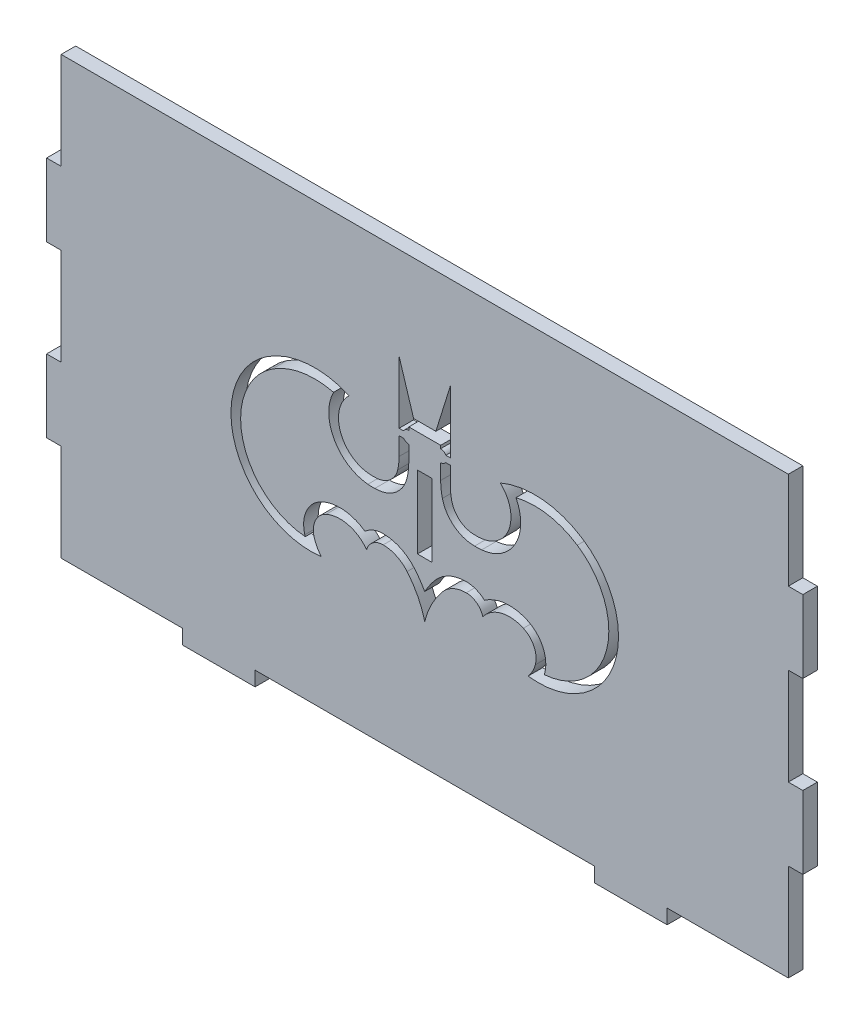
from build123d import *

# Parameters (mm, degrees)
BOSS_EXTRUDE1_DEPTH = 3
SKETCH2_W           = 3
SKETCH2_H           = 15
CUT_EXTRUDE1_DEPTH  = 10
CUT_EXTRUDE5_DEPTH  = 10


with BuildPart() as part:
    # Sketch1 → Boss-Extrude1 (new body)
    with BuildSketch(Plane.XY):
        Polygon((75, 45), (-75, 45), (-75, 25), (-78, 25), (-78, 10), (-75, 10), (-75, -10), (-78, -10), (-78, -25), (-75, -25), (-75, -45), (-50, -45), (-50, -48), (-35, -48), (-35, -45), (35, -45), (35, -48), (50, -48), (50, -45), (75, -45), (75, -25), (78, -25), (78, -10), (75, -10), (75, 10), (78, 10), (78, 25), (75, 25), align=None)
    extrude(amount=BOSS_EXTRUDE1_DEPTH)

    # Sketch2 → Cut-Extrude1 (cut)
    with BuildSketch(Plane.XY.offset(3)):
        Rectangle(SKETCH2_W, SKETCH2_H)
    extrude(amount=-CUT_EXTRUDE1_DEPTH, mode=Mode.SUBTRACT)

    # Sketch6 → Cut-Extrude5 (cut)
    with BuildSketch(Plane.XY.offset(3)):
        with BuildLine():
            Line((5.290512726, 25.935056248), (2.295363862, 16.311934545))
            Line((2.295363862, 16.311934545), (-2.295363862, 16.311934545))
            Line((-2.295363862, 16.311934545), (-5.290512726, 25.935056248))
            Line((-5.290512726, 25.935056248), (-5.287204108, 13.065687756))
            Line((-5.287204108, 13.065687756), (-4.373165869, 13.065687756))
            ThreePointArc((-4.373165869, 13.065687756), (-3.915305203, 13.527588879), (-3.287366333, 13.696945937))
            Line((-3.287366333, 13.696945937), (-3.287524442, 14.311934545))
            Line((-3.287524442, 14.311934545), (3.287524442, 14.311934545))
            Line((3.287524442, 14.311934545), (3.287366333, 13.696945937))
            ThreePointArc((3.287366333, 13.696945937), (3.915305203, 13.527588879), (4.373165869, 13.065687756))
            Line((4.373165869, 13.065687756), (5.287204108, 13.065687756))
            Line((5.287204108, 13.065687756), (5.290512726, 25.935056248))
        make_face()
        with BuildLine():
            Line((5.285908962, 8.028025182), (5.2868631, 11.739287))
            Line((5.2868631, 11.739287), (4.317442352, 11.739287))
            ThreePointArc((4.317442352, 11.739287), (3.869108183, 11.340735142), (3.286723602, 11.19694602))
            Line((3.286723602, 11.19694602), (3.285909029, 8.028539367))
            ThreePointArc((3.285909029, 8.028539367), (3.374432245, 6.505542997), (3.639582158, 5.003194892))
            ThreePointArc((3.639582158, 5.003194892), (6.055992917, 1.239562801), (10.295107821, -0.186576152))
            ThreePointArc((10.295107821, -0.186576152), (11.01438813, -0.194494412), (11.732516685, -0.153042755))
            ThreePointArc((11.732516685, -0.153042755), (18.692972821, 4.404939535), (18.821664118, 12.723989405))
            ThreePointArc((18.821664118, 12.723989405), (25.37715821, 12.9694755), (31.476327164, 10.553920845))
            ThreePointArc((31.476327164, 10.553920845), (37.518458896, -5.149561028), (24.647485484, -15.98675357))
            ThreePointArc((24.647485484, -15.98675357), (24.695354215, -15.831004559), (24.740416096, -15.674420407))
            ThreePointArc((24.740416096, -15.674420407), (24.374260224, -11.19523634), (21.190905903, -8.022947688))
            ThreePointArc((21.190905903, -8.022947688), (16.646624705, -7.250909085), (12.327665086, -8.861226761))
            ThreePointArc((12.327665086, -8.861226761), (10.583620787, -7.776302438), (8.564637884, -7.398864573))
            ThreePointArc((8.564637884, -7.398864573), (5.000034739, -8.19121848), (2.10219111, -10.413092149))
            ThreePointArc((2.10219111, -10.413092149), (0.980226646, -11.88188736), (0, -13.448833229))
            ThreePointArc((0, -13.448833229), (-0.980226646, -11.88188736), (-2.10219111, -10.413092149))
            ThreePointArc((-2.10219111, -10.413092149), (-5.000034739, -8.19121848), (-8.564637884, -7.398864573))
            ThreePointArc((-8.564637884, -7.398864573), (-10.583620787, -7.776302438), (-12.327665086, -8.861226761))
            ThreePointArc((-12.327665086, -8.861226761), (-16.646624705, -7.250909085), (-21.190905903, -8.022947688))
            ThreePointArc((-21.190905903, -8.022947688), (-24.374260224, -11.19523634), (-24.740416096, -15.674420407))
            ThreePointArc((-24.740416096, -15.674420407), (-24.695354215, -15.831004559), (-24.647485484, -15.98675357))
            ThreePointArc((-24.647485484, -15.98675357), (-37.518458896, -5.149561028), (-31.476327164, 10.553920845))
            ThreePointArc((-31.476327164, 10.553920845), (-25.37715821, 12.9694755), (-18.821664118, 12.723989405))
            ThreePointArc((-18.821664118, 12.723989405), (-18.692972821, 4.404939535), (-11.732516685, -0.153042755))
            ThreePointArc((-11.732516685, -0.153042755), (-11.01438813, -0.194494412), (-10.295107821, -0.186576152))
            ThreePointArc((-10.295107821, -0.186576152), (-6.055992917, 1.239562801), (-3.639582158, 5.003194892))
            ThreePointArc((-3.639582158, 5.003194892), (-3.374432245, 6.505542997), (-3.285909029, 8.028539367))
            Line((-3.285909029, 8.028539367), (-3.286723602, 11.19694602))
            ThreePointArc((-3.286723602, 11.19694602), (-3.869108183, 11.340735142), (-4.317442352, 11.739287))
            Line((-4.317442352, 11.739287), (-5.2868631, 11.739287))
            Line((-5.2868631, 11.739287), (-5.285908962, 8.028025182))
            ThreePointArc((-5.285908962, 8.028025182), (-5.360904336, 6.737768387), (-5.585534863, 5.465004453))
            ThreePointArc((-5.585534863, 5.465004453), (-7.308177113, 2.799425217), (-10.325195997, 1.814333325))
            ThreePointArc((-10.325195997, 1.814333325), (-10.937431926, 1.804308669), (-11.548794517, 1.838500909))
            ThreePointArc((-11.548794517, 1.838500909), (-17.428845514, 6.476374098), (-15.585134149, 13.734858501))
            ThreePointArc((-15.585134149, 13.734858501), (-24.273750539, 15.128136766), (-32.579650708, 12.222056678))
            ThreePointArc((-32.579650708, 12.222056678), (-38.93241703, -7.310810177), (-21.328283314, -17.893106884))
            ThreePointArc((-21.328283314, -17.893106884), (-22.225314868, -16.599112533), (-22.8135279, -15.138601519))
            ThreePointArc((-22.8135279, -15.138601519), (-22.559974367, -12.036881652), (-20.355583301, -9.840153276))
            ThreePointArc((-20.355583301, -9.840153276), (-15.796843839, -9.421233335), (-11.984787413, -11.956154477))
            ThreePointArc((-11.984787413, -11.956154477), (-10.701852428, -10.107966912), (-8.56669627, -9.398863514))
            ThreePointArc((-8.56669627, -9.398863514), (-5.845441544, -10.003754641), (-3.633197893, -11.699955866))
            ThreePointArc((-3.633197893, -11.699955866), (-1.414932414, -15.040464669), (0, -18.7924864))
            ThreePointArc((0, -18.7924864), (1.414932414, -15.040464669), (3.633197893, -11.699955866))
            ThreePointArc((3.633197893, -11.699955866), (5.845441544, -10.003754641), (8.56669627, -9.398863514))
            ThreePointArc((8.56669627, -9.398863514), (10.701852428, -10.107966912), (11.984787413, -11.956154477))
            ThreePointArc((11.984787413, -11.956154477), (15.796843839, -9.421233335), (20.355583301, -9.840153276))
            ThreePointArc((20.355583301, -9.840153276), (22.559974367, -12.036881652), (22.8135279, -15.138601519))
            ThreePointArc((22.8135279, -15.138601519), (22.225314868, -16.599112533), (21.328283314, -17.893106884))
            ThreePointArc((21.328283314, -17.893106884), (38.93241703, -7.310810177), (32.579650708, 12.222056678))
            ThreePointArc((32.579650708, 12.222056678), (24.273750539, 15.128136766), (15.585134149, 13.734858501))
            ThreePointArc((15.585134149, 13.734858501), (17.428845514, 6.476374098), (11.548794517, 1.838500909))
            ThreePointArc((11.548794517, 1.838500909), (10.937431926, 1.804308669), (10.325195997, 1.814333325))
            ThreePointArc((10.325195997, 1.814333325), (7.308177113, 2.799425217), (5.585534863, 5.465004453))
            ThreePointArc((5.585534863, 5.465004453), (5.360904336, 6.737768387), (5.285908962, 8.028025182))
        make_face()
    extrude(amount=-CUT_EXTRUDE5_DEPTH, mode=Mode.SUBTRACT)


solid = part.part
